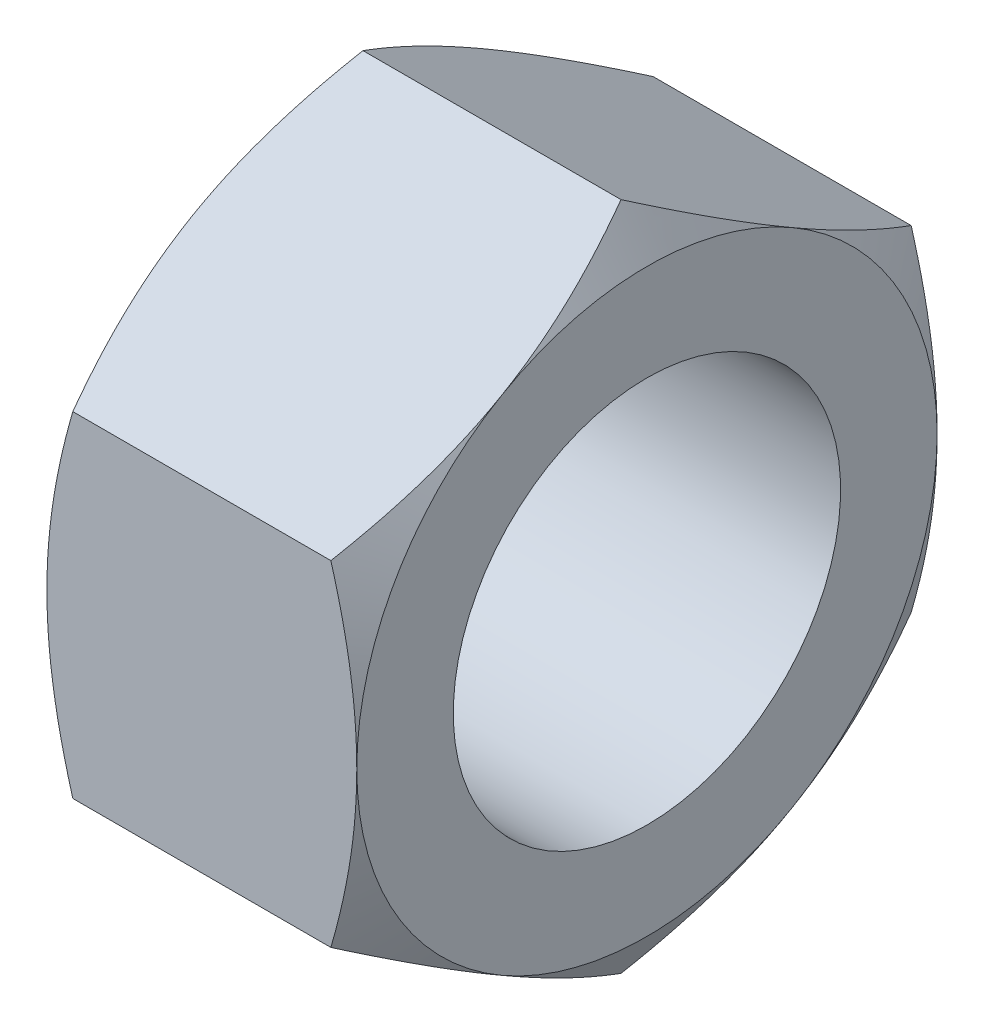
from build123d import *

# Parameters (mm, degrees)
CROQUIS1_W            = 6.4
CROQUIS1_H            = 6.92
CORTAR_EXTRUIR1_DEPTH = 7
CROQUIS3_OUTSIDE_W    = 42.114
CROQUIS3_OUTSIDE_H    = 43.968
CROQUIS3_OUTSIDE_R    = 5.992895794
CORTAR_EXTRUIR2_DEPTH = 7
CORTAR_EXTRUIR2_TAPER = 60
CROQUIS5_OUTSIDE_W    = 21.33
CROQUIS5_OUTSIDE_H    = 23.184
CROQUIS5_OUTSIDE_R    = 5.992895794
CORTAR_EXTRUIR3_DEPTH = 1
CORTAR_EXTRUIR3_TAPER = 60
CROQUIS6_R            = 4
CORTAR_EXTRUIR4_DEPTH = 7


with BuildPart() as part:
    # Croquis1 → Revolución1 (revolve)
    with BuildSketch(Plane.XY):
        with Locations((3.2, 3.46)):
            Rectangle(CROQUIS1_W, CROQUIS1_H)
    revolve(axis=Axis((6.4, 0, 0), (-1, 0, 0)))

    # Croquis2 → Cortar-Extruir1 (cut)
    with BuildSketch(Plane(origin=(6.4, 0, 0), x_dir=(0, 0, -1), z_dir=(1, 0, 0))):
        with BuildLine():
            Line((-5.992895794, -3.46), (-5.992895794, 3.46))
            ThreePointArc((-5.992895794, 3.46), (-6.92, 0), (-5.992895794, -3.46))
        make_face()
        with BuildLine():
            Line((-5.992895794, 3.46), (0, 6.92))
            ThreePointArc((0, 6.92), (-3.46, 5.992895794), (-5.992895794, 3.46))
        make_face()
        with BuildLine():
            ThreePointArc((5.992895794, 3.46), (3.46, 5.992895794), (0, 6.92))
            Line((0, 6.92), (5.992895794, 3.46))
        make_face()
        with BuildLine():
            ThreePointArc((6.92, 0), (6.684206718, 1.791027792), (5.992895794, 3.46))
            Line((5.992895794, 3.46), (5.992895794, -3.46))
            ThreePointArc((5.992895794, -3.46), (6.684206718, -1.791027792), (6.92, 0))
        make_face()
        with BuildLine():
            ThreePointArc((0, -6.92), (3.46, -5.992895794), (5.992895794, -3.46))
            Line((5.992895794, -3.46), (0, -6.92))
        make_face()
        with BuildLine():
            Line((0, -6.92), (-5.992895794, -3.46))
            ThreePointArc((-5.992895794, -3.46), (-3.46, -5.992895794), (0, -6.92))
        make_face()
    extrude(amount=-CORTAR_EXTRUIR1_DEPTH, mode=Mode.SUBTRACT)

    # Croquis3 outside → Cortar-Extruir2 (cut)
    with BuildSketch(Plane(origin=(6.4, 0, 0), x_dir=(0, 0, -1), z_dir=(1, 0, 0))):
        Rectangle(CROQUIS3_OUTSIDE_W, CROQUIS3_OUTSIDE_H)
        Circle(CROQUIS3_OUTSIDE_R, mode=Mode.SUBTRACT)
    extrude(amount=-CORTAR_EXTRUIR2_DEPTH, taper=CORTAR_EXTRUIR2_TAPER, mode=Mode.SUBTRACT)

    # Croquis5 outside → Cortar-Extruir3 (cut)
    with BuildSketch(Plane.ZY):
        Rectangle(CROQUIS5_OUTSIDE_W, CROQUIS5_OUTSIDE_H)
        Circle(CROQUIS5_OUTSIDE_R, mode=Mode.SUBTRACT)
    extrude(amount=-CORTAR_EXTRUIR3_DEPTH, taper=CORTAR_EXTRUIR3_TAPER, mode=Mode.SUBTRACT)

    # Croquis6 → Cortar-Extruir4 (cut)
    with BuildSketch(Plane(origin=(6.4, 0, 0), x_dir=(0, 0, -1), z_dir=(1, 0, 0))):
        Circle(CROQUIS6_R)
    extrude(amount=-CORTAR_EXTRUIR4_DEPTH, mode=Mode.SUBTRACT)


solid = part.part
